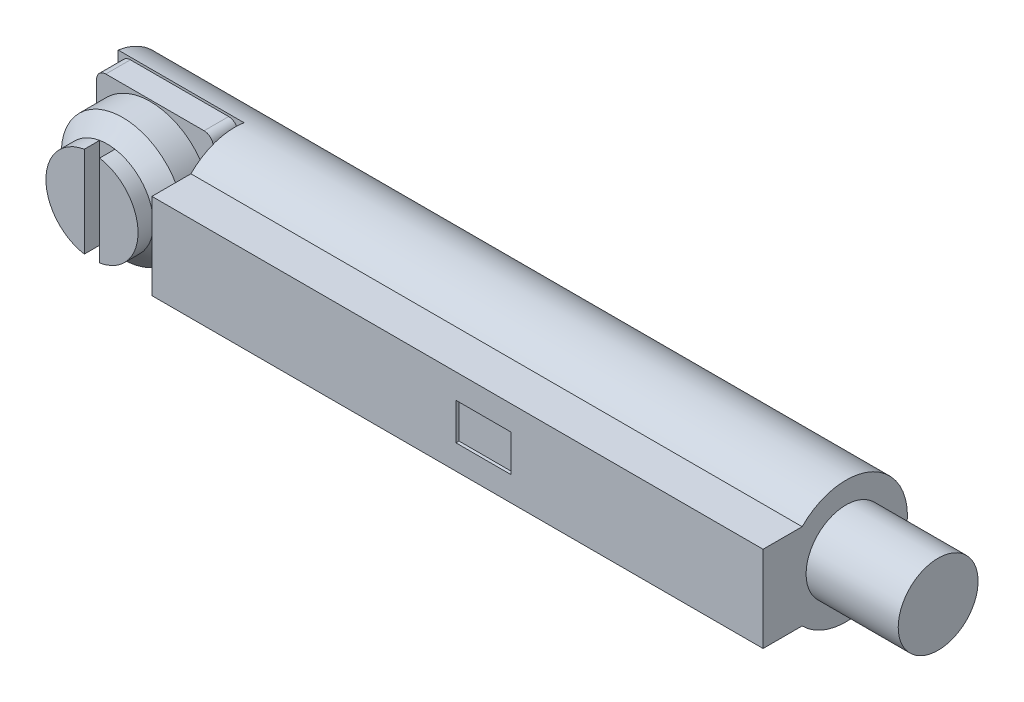
from build123d import *

# Parameters (mm, degrees)
BOSS_EXTRUDE1_DEPTH     = 24
SKETCH2_W               = 3
SKETCH2_H               = 4
CUT_EXTRUDE1_DEPTH      = 4.1
BOSS_EXTRUDE2_DEPTH     = 0.8
SKETCH5_W               = 0.5
SKETCH5_H               = 0.5
CUT_EXTRUDE2_DEPTH      = 2
CUT_EXTRUDE2_DEPTH_BACK = 2
SKETCH6_W               = 1.8
SKETCH6_H               = 1.2
CUT_EXTRUDE3_DEPTH      = 0.1
SKETCH7_W               = 3
SKETCH7_H               = 1.3


with BuildPart() as part:
    # Sketch1 → Boss-Extrude1 (new body)
    with BuildSketch(Plane(origin=(0, 0, 0), x_dir=(0, 0, -1), z_dir=(1, 0, 0))):
        with BuildLine():
            Line((-2.7, 0.6), (-1.428285686, 0.6))
            ThreePointArc((-1.428285686, 0.6), (2, 2), (-1.428285686, 3.4))
            Line((-1.428285686, 3.4), (-2.7, 3.4))
            Line((-2.7, 3.4), (-2.7, 0.6))
        make_face()
    extrude(amount=BOSS_EXTRUDE1_DEPTH)

    # Sketch2 → Cut-Extrude1 (cut)
    with BuildSketch(Plane(origin=(0, 0, 0), x_dir=(0, 0, -1), z_dir=(1, 0, 0))):
        with Locations((-1.2, 2)):
            Rectangle(SKETCH2_W, SKETCH2_H)
    extrude(amount=CUT_EXTRUDE1_DEPTH, mode=Mode.SUBTRACT)

    # Sketch3 → Boss-Extrude2 (add)
    with BuildSketch(Plane.XY.offset(-0.3)):
        with BuildLine():
            Line((0.4, 0.1), (3.6, 0.1))
            ThreePointArc((3.6, 0.1), (3.812132034, 0.187867966), (3.9, 0.4))
            Line((3.9, 0.4), (3.9, 3.6))
            ThreePointArc((3.9, 3.6), (3.812132034, 3.812132034), (3.6, 3.9))
            Line((3.6, 3.9), (0.4, 3.9))
            ThreePointArc((0.4, 3.9), (0.187867966, 3.812132034), (0.1, 3.6))
            Line((0.1, 3.6), (0.1, 0.4))
            ThreePointArc((0.1, 0.4), (0.187867966, 0.187867966), (0.4, 0.1))
        make_face()
    extrude(amount=BOSS_EXTRUDE2_DEPTH)

    # Sketch4 → Revolve1 (revolve)
    with BuildSketch(Plane(origin=(0, 2, 0), x_dir=(-1, 0, 0), z_dir=(0, 1, 0))):
        Polygon((-2, 2.55), (-0.5, 2.55), (-0.5, 2.05), (0, 1.55), (0, 0.65), (-1.25, 0.65), (-1.25, 0.3), (-2, 0.3), align=None)
    revolve(axis=Axis((2, 2, 0.3), (0, 0, 1)))

    # Sketch5 → Cut-Extrude2 (cut, two sides)
    with BuildSketch(Plane(origin=(0, 2, 0), x_dir=(-1, 0, 0), z_dir=(0, 1, 0))) as cut_extrude2_sk:
        with Locations((-2, 2.3)):
            Rectangle(SKETCH5_W, SKETCH5_H)
    extrude(amount=CUT_EXTRUDE2_DEPTH, mode=Mode.SUBTRACT)
    extrude(cut_extrude2_sk.sketch, amount=-CUT_EXTRUDE2_DEPTH_BACK, mode=Mode.SUBTRACT)

    # Sketch6 → Cut-Extrude3 (cut)
    with BuildSketch(Plane.XY.offset(2.7)):
        with Locations((14.9, 2)):
            Rectangle(SKETCH6_W, SKETCH6_H)
    extrude(amount=-CUT_EXTRUDE3_DEPTH, mode=Mode.SUBTRACT)

    # Sketch7 → Revolve2 (revolve)
    with BuildSketch(Plane(origin=(0, 2, 0), x_dir=(-1, 0, 0), z_dir=(0, 1, 0))):
        with Locations((-25.5, -0.65)):
            Rectangle(SKETCH7_W, SKETCH7_H)
    revolve(axis=Axis((27, 2, 0), (-1, 0, 0)))


solid = part.part
